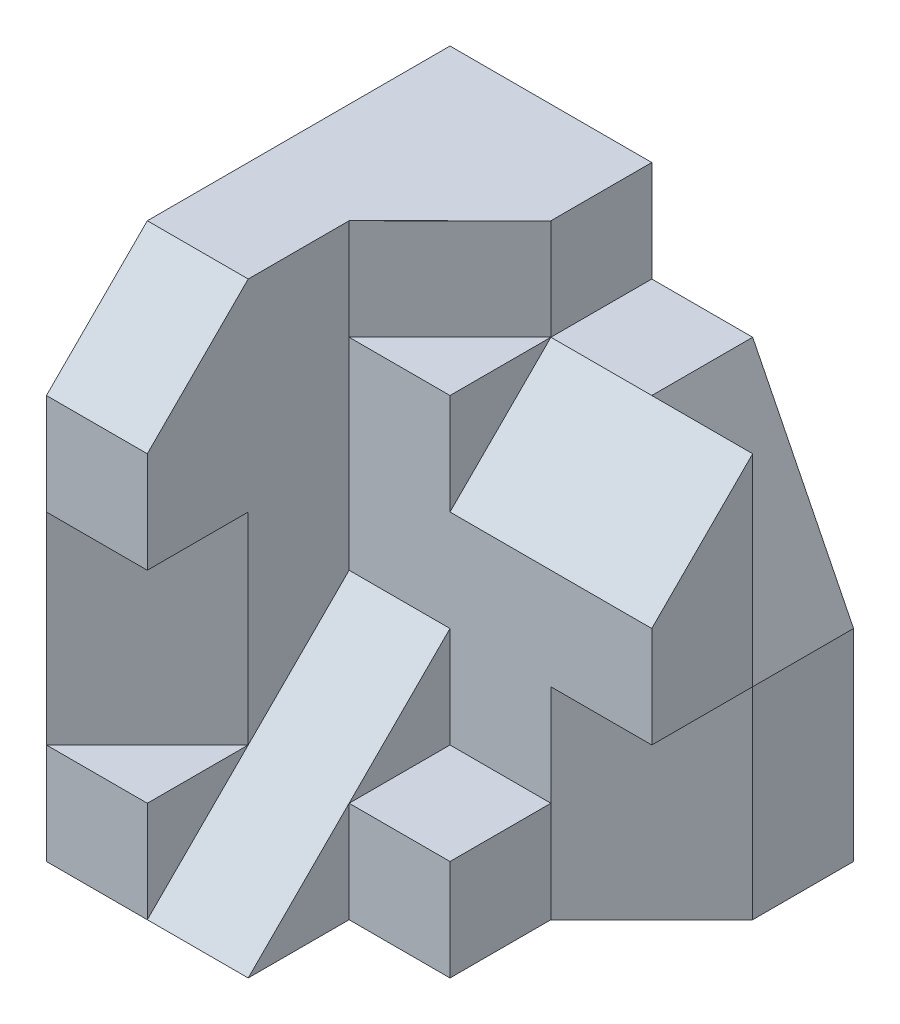
from build123d import *

# Parameters (mm, degrees)
SKETCH1_W           = 4
SKETCH1_H           = 5
BOSS_EXTRUDE1_DEPTH = 4
CUT_EXTRUDE1_DEPTH  = 5
CUT_EXTRUDE2_DEPTH  = 1
CUT_EXTRUDE3_DEPTH  = 1
CUT_EXTRUDE4_DEPTH  = 2
SKETCH6_W           = 2
SKETCH6_H           = 2
CUT_EXTRUDE5_DEPTH  = 4
CUT_EXTRUDE6_DEPTH  = 2
CUT_EXTRUDE7_DEPTH  = 1
CUT_EXTRUDE8_DEPTH  = 2
SKETCH12_W          = 1.414213562
SKETCH12_H          = 2
CUT_EXTRUDE9_DEPTH  = 3.828427125


with BuildPart() as part:
    # Sketch1 → Boss-Extrude1 (new body)
    with BuildSketch(Plane.XY):
        Rectangle(SKETCH1_W, SKETCH1_H)
    extrude(amount=BOSS_EXTRUDE1_DEPTH)

    # Sketch2 → Cut-Extrude1 (cut, through all)
    with BuildSketch(Plane(origin=(2, 0, 0), x_dir=(0, 0, -1), z_dir=(1, 0, 0))):
        Polygon((-3, 2.5), (-4, 1.5), (-4, 2.5), align=None)
    extrude(amount=-CUT_EXTRUDE1_DEPTH, mode=Mode.SUBTRACT)

    # Sketch3 → Cut-Extrude2 (cut)
    with BuildSketch(Plane(origin=(0, 2.5, 0), x_dir=(1, 0, 0), z_dir=(0, 1, 0))):
        Polygon((2, 0), (0, 0), (0, -1), (-1, -2), (-1, -3), (2, -3), align=None)
    extrude(amount=-CUT_EXTRUDE2_DEPTH, mode=Mode.SUBTRACT)

    # Sketch4 → Cut-Extrude3 (cut)
    with BuildSketch(Plane(origin=(0, 0, 0), x_dir=(-1, 0, 0), z_dir=(0, 0, -1))):
        Polygon((-2, 1.5), (-1, 1.5), (-2, -0.5), align=None)
    extrude(amount=-CUT_EXTRUDE3_DEPTH, mode=Mode.SUBTRACT)

    # Sketch5 → Cut-Extrude4 (cut)
    with BuildSketch(Plane(origin=(2, 0, 0), x_dir=(0, 0, -1), z_dir=(1, 0, 0))):
        Polygon((-1, 1.5), (-2, 0.5), (-2, 1.5), align=None)
    extrude(amount=-CUT_EXTRUDE4_DEPTH, mode=Mode.SUBTRACT)

    # Sketch6 → Cut-Extrude5 (cut)
    with BuildSketch(Plane(origin=(0, 2.5, 0), x_dir=(1, 0, 0), z_dir=(0, 1, 0))):
        with Locations((1, -3)):
            Rectangle(SKETCH6_W, SKETCH6_H)
    extrude(amount=-CUT_EXTRUDE5_DEPTH, mode=Mode.SUBTRACT)

    # Sketch7 → Cut-Extrude6 (cut, through all)
    with BuildSketch(Plane(origin=(0, -1.5, 0), x_dir=(1, 0, 0), z_dir=(0, 1, 0))):
        Polygon((2, -2), (1, -2), (1, -3), (0, -3), (0, -4), (2, -4), align=None)
    extrude(amount=-CUT_EXTRUDE6_DEPTH, mode=Mode.SUBTRACT)

    # Sketch8 → Cut-Extrude7 (cut)
    with BuildSketch(Plane(origin=(0, 0, 0), x_dir=(0, 0, -1), z_dir=(1, 0, 0))):
        Polygon((-2, -0.5), (-4, -2.5), (-4, 2.5), (-2, 2.5), align=None)
    extrude(amount=-CUT_EXTRUDE7_DEPTH, mode=Mode.SUBTRACT)

    # Sketch9 → Cut-Extrude8 (cut)
    with BuildSketch(Plane.XZ.offset(2.5)):
        Polygon((1, 2), (2, 1), (2, 2), align=None)
    extrude(amount=-CUT_EXTRUDE8_DEPTH, mode=Mode.SUBTRACT)

    # Sketch12 → Cut-Extrude9 (cut, through all)
    with BuildSketch(Plane(origin=(1, 0, 1), x_dir=(-0.707106781, 0, 0.707106781), z_dir=(-0.707106781, 0, -0.707106781))):
        with Locations((3.535533906, -0.5)):
            Rectangle(SKETCH12_W, SKETCH12_H)
    extrude(amount=-CUT_EXTRUDE9_DEPTH, mode=Mode.SUBTRACT)


solid = part.part
